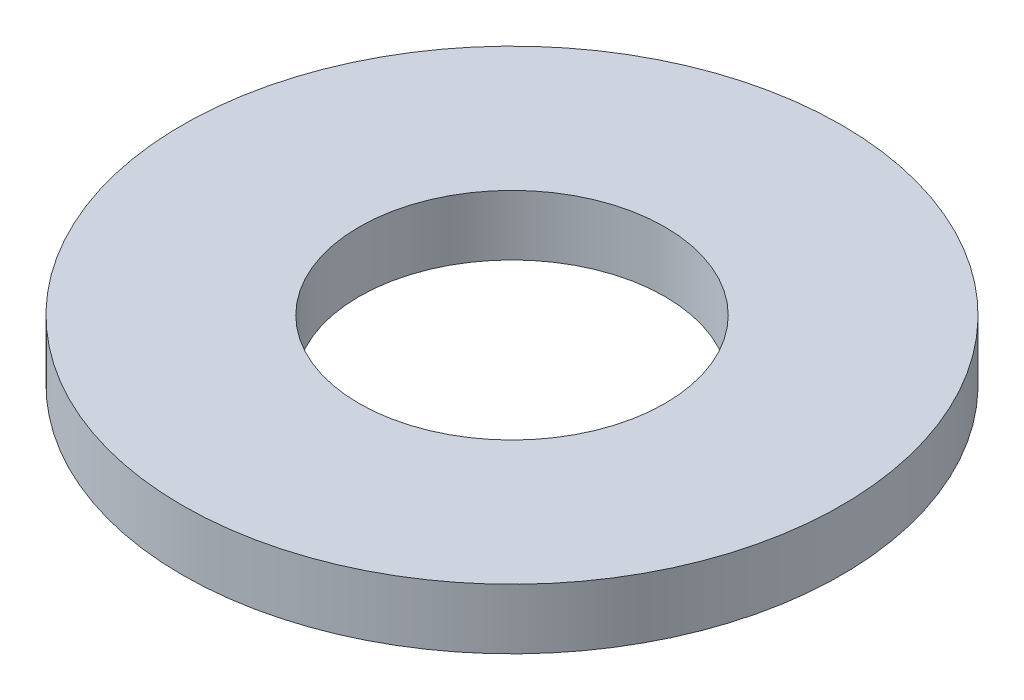
from build123d import *

# Parameters (mm, degrees)
SKETCH1_R           = 5.55625
BOSS_EXTRUDE1_DEPTH = 1.016
SKETCH5_R           = 2.5781
CUT_EXTRUDE1_DEPTH  = 2.016


with BuildPart() as part:
    # Sketch1 → Boss-Extrude1 (new body)
    with BuildSketch(Plane(origin=(0, 0, 0), x_dir=(1, 0, 0), z_dir=(0, 1, 0))):
        Circle(SKETCH1_R)
    extrude(amount=BOSS_EXTRUDE1_DEPTH)

    # Sketch5 → Cut-Extrude1 (cut, through all)
    with BuildSketch(Plane(origin=(0, 1.016, 0), x_dir=(-1, 0, 0), z_dir=(0, 1, 0))):
        Circle(SKETCH5_R)
    extrude(amount=-CUT_EXTRUDE1_DEPTH, mode=Mode.SUBTRACT)


solid = part.part
